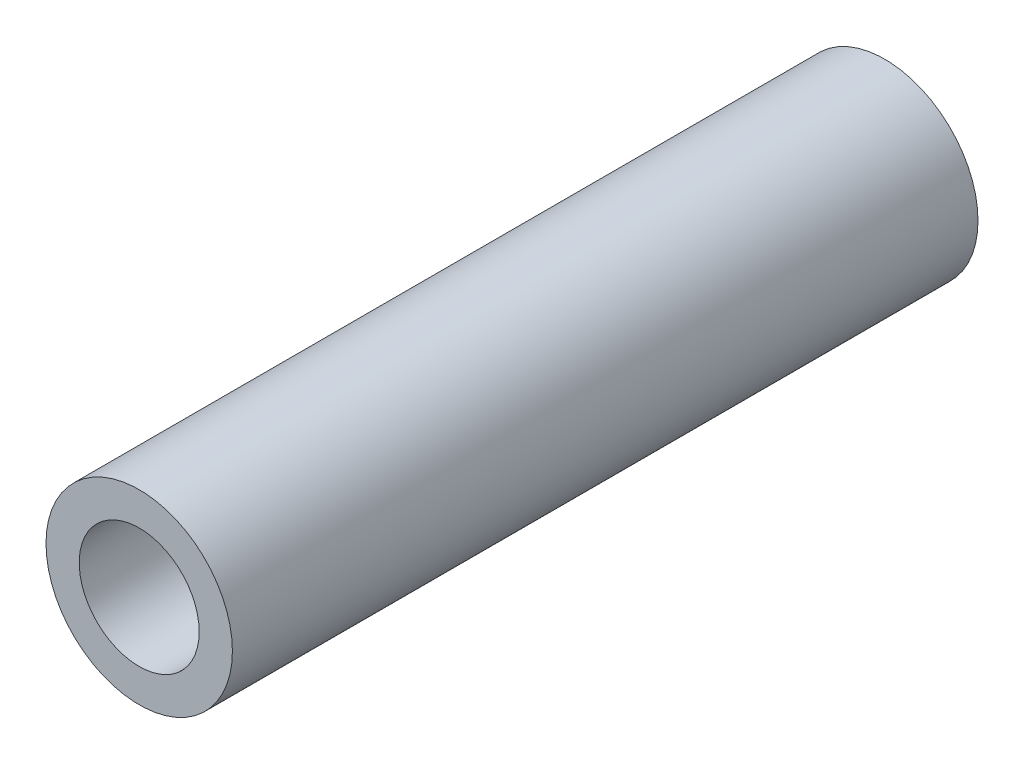
from build123d import *

# Parameters (mm, degrees)
SKETCH1_R           = 3.96875
SKETCH1_R_2         = 2.555
BOSS_EXTRUDE1_DEPTH = 31.75


with BuildPart() as part:
    # Sketch1 → Boss-Extrude1 (new body)
    with BuildSketch(Plane.XY):
        Circle(SKETCH1_R)
        Circle(SKETCH1_R_2, mode=Mode.SUBTRACT)
    extrude(amount=BOSS_EXTRUDE1_DEPTH)


solid = part.part
